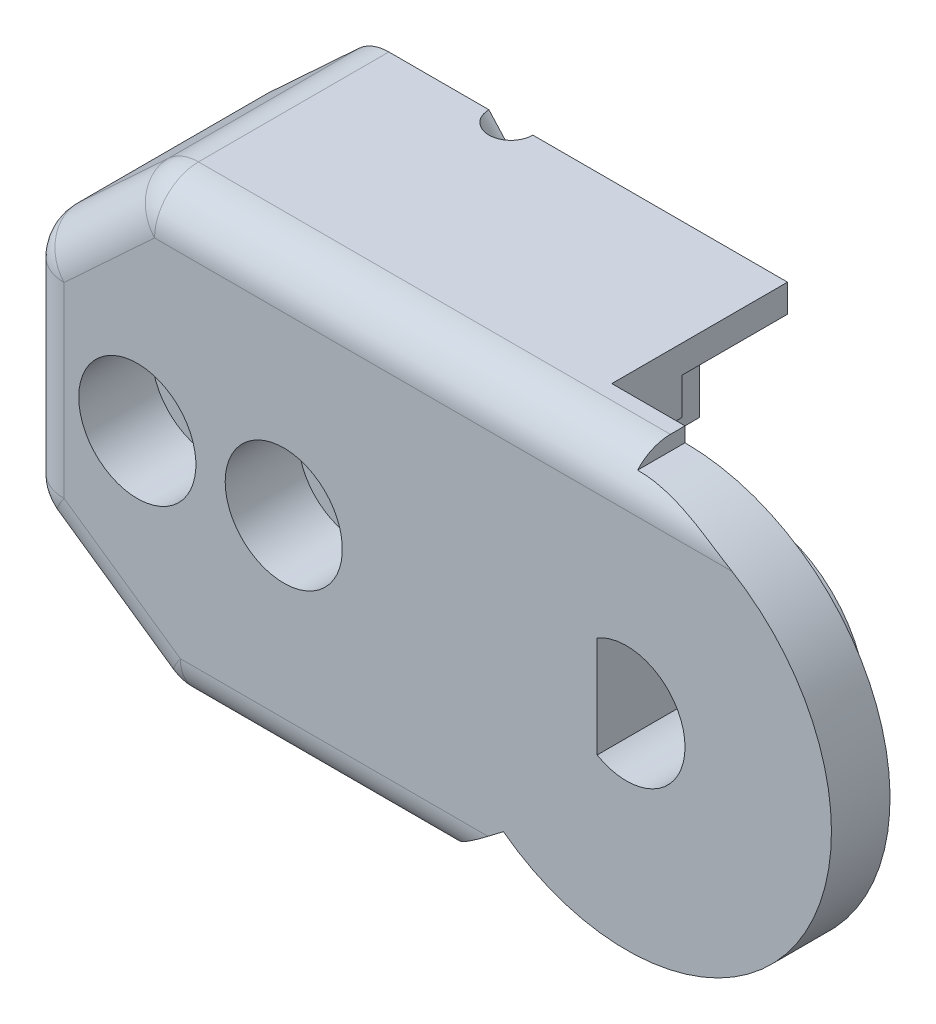
from build123d import *

# Parameters (mm, degrees)
BOSS_EXTRUDE1_DEPTH = 2
BOSS_EXTRUDE2_DEPTH = 6
SKETCH24_R          = 3.9
BOSS_EXTRUDE5_DEPTH = 2.3
SKETCH30_W          = 2.408612022
SKETCH30_H          = 1.324178481
CUT_EXTRUDE12_DEPTH = 8
CUT_EXTRUDE11_DEPTH = 5.3
FILLET1_R           = 1.5
SKETCH34_R          = 0.75
CUT_EXTRUDE13_DEPTH = 8
SKETCH35_R          = 0.75
CUT_EXTRUDE14_DEPTH = 4
SKETCH36_R          = 0.95
CUT_EXTRUDE15_DEPTH = 8
SKETCH37_R          = 2
CUT_EXTRUDE16_DEPTH = 2.5
SKETCH38_W          = 3
SKETCH38_H          = 1.25
CUT_EXTRUDE17_DEPTH = 3.6


with BuildPart() as part:
    # Sketch2 → Boss-Extrude1 (new body)
    with BuildSketch(Plane.XY):
        with BuildLine():
            Line((-2.5, 7.5), (-16.7, 7.5))
            Line((-16.7, 7.5), (-20.7, 3.793442666))
            Line((-20.7, 3.793442666), (-20.7, -4.031648778))
            Line((-20.7, -4.031648778), (-15.7, -7.5))
            Line((-15.7, -7.5), (-6.7, -7.5))
            Line((-6.7, -7.5), (-4.2, -5.6))
            ThreePointArc((-4.2, -5.6), (3.130495168, -6.260990337), (7, 0))
            ThreePointArc((7, 0), (4.949747468, 4.949747468), (0, 7))
            Line((0, 7), (0, 7.5))
            Line((0, 7.5), (-2.5, 7.5))
        make_face()
    extrude(amount=BOSS_EXTRUDE1_DEPTH)

    # Sketch4 → Boss-Extrude2 (add)
    with BuildSketch(Plane.XY.offset(2)):
        Polygon((-15.7, -7.5), (-6.7, -7.5), (-6.759079174, -4.5), (-7.7, -4.5), (-7.7, 2), (-5.5, 2), (-5.5, 5.3), (-2.5, 5.3), (-2.5, 7.5), (-16.7, 7.5), (-20.7, 3.793442666), (-20.7, -4.031648778), align=None)
    extrude(amount=BOSS_EXTRUDE2_DEPTH)

    # Sketch24 → Boss-Extrude5 (add)
    with BuildSketch(Plane.XY.offset(2)):
        Circle(SKETCH24_R)
    extrude(amount=BOSS_EXTRUDE5_DEPTH)

    # Sketch30 → Cut-Extrude12 (cut)
    with BuildSketch(Plane(origin=(-5.5, 0, 0), x_dir=(0, 0, -1), z_dir=(1, 0, 0))):
        with Locations((-3.261593395, 4.63791076)):
            Rectangle(SKETCH30_W, SKETCH30_H)
    extrude(amount=-CUT_EXTRUDE12_DEPTH, mode=Mode.SUBTRACT)

    # Sketch28 → Cut-Extrude11 (cut, through all)
    with BuildSketch(Plane.XY.offset(4.3)):
        with BuildLine():
            Line((-1, 1.732050808), (-1, -1.732050808))
            ThreePointArc((-1, -1.732050808), (2, 0), (-1, 1.732050808))
        make_face()
    extrude(amount=-CUT_EXTRUDE11_DEPTH, mode=Mode.SUBTRACT)

    # Fillet1
    fillet1_edges = [part.edges().sort_by_distance(p)[0] for p in [
        (-11.2, -7.5, 0),
        (-8.35, 7.5, 0),
        (-18.7, 5.646721333, 0),
        (-18.2, -5.765824389, 0),
        (-20.7, -0.119103056, 0),
        (-15.7, -7.5, 4),
        (-20.7, -4.031648778, 4),
        (-20.7, 3.793442666, 4),
        (-16.7, 7.5, 4),
    ]]
    fillet(fillet1_edges, radius=FILLET1_R)

    # Sketch34 → Cut-Extrude13 (cut, along a direction that is not the sketch's normal)
    with BuildSketch(Plane.XZ.offset(-2)):
        with Locations((-7, 8)):
            Circle(SKETCH34_R)
    extrude(amount=-CUT_EXTRUDE13_DEPTH, dir=(0.668583388, -0.743637179, 0), mode=Mode.SUBTRACT)

    # Sketch35 → Cut-Extrude14 (cut, symmetric, along a direction that is not the sketch's normal)
    with BuildSketch(Plane(origin=(0, -4.5, 0), x_dir=(1, 0, 0), z_dir=(0, 1, 0))):
        with Locations((-8.259079174, -8)):
            Circle(SKETCH35_R)
    extrude(amount=CUT_EXTRUDE14_DEPTH, dir=(0.599919418, 0.80006043, 0), both=True, mode=Mode.SUBTRACT)

    # Sketch36 → Cut-Extrude15 (cut)
    with BuildSketch(Plane.XY.offset(8)):
        with Locations((-11.7, 0)):
            Circle(SKETCH36_R)
        with Locations((-16.7, 0)):
            Circle(SKETCH36_R)
    extrude(amount=-CUT_EXTRUDE15_DEPTH, mode=Mode.SUBTRACT)

    # Sketch37 → Cut-Extrude16 (cut)
    with BuildSketch(Plane(origin=(0, 0, 0), x_dir=(-1, 0, 0), z_dir=(0, 0, -1))):
        with Locations((11.7, 0)):
            Circle(SKETCH37_R)
        with Locations((16.7, 0)):
            Circle(SKETCH37_R)
    extrude(amount=-CUT_EXTRUDE16_DEPTH, mode=Mode.SUBTRACT)

    # Sketch38 → Cut-Extrude17 (cut)
    with BuildSketch(Plane.XY.offset(8)):
        with Locations((-4, 5.925)):
            Rectangle(SKETCH38_W, SKETCH38_H)
    extrude(amount=-CUT_EXTRUDE17_DEPTH, mode=Mode.SUBTRACT)

    # Mirror1: part across plane


with BuildPart() as part_1:
    add(part.part)
    add(part.part.mirror(Plane.XY.offset(8)))


with BuildPart() as body_2:
    # Split1: the piece on the far side of the plane
    add(part_1.part)
    split(bisect_by=Plane.XY.offset(8), keep=Keep.BOTTOM)


with BuildPart() as part_2:
    add(part_1.part)

    # Split1
    split(bisect_by=Plane.XY.offset(8), keep=Keep.TOP)


solid = part_2.part
